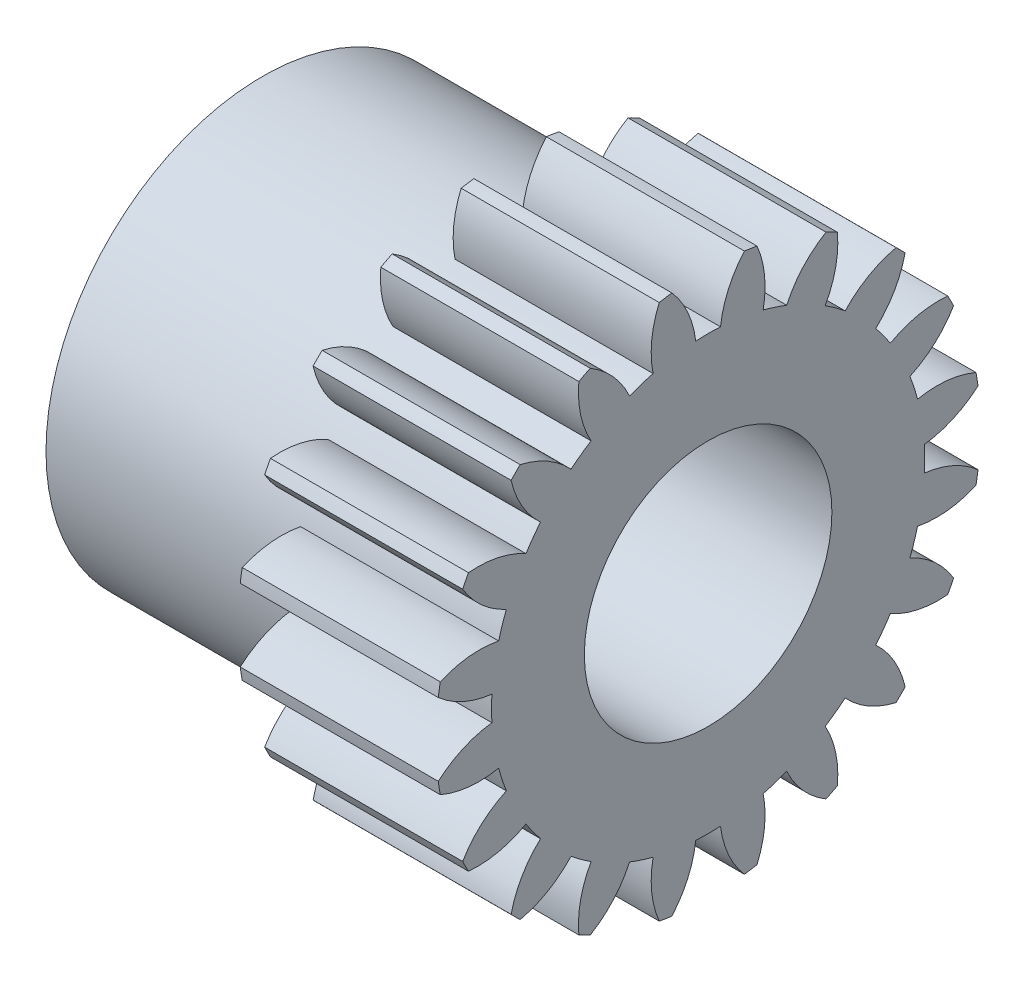
from build123d import *
from build123d.topology import SkipClean

# Parameters (mm, degrees)
BASPROSKE_W         = 5
BASPROSKE_H         = 5.5
TOOTHCUT_DEPTH      = 10.246621004
TEETHCUTS_COUNT     = 20
TEETHCUTS_ANGLE     = 342
HUBNEAONESKE_R      = 4.374
HUBNEARONE_DEPTH    = 5.0000508
BORSKE_R            = 2.5
BORE_DEPTH          = 10.0000508
SKETCH_1_R          = 5.5
CUT_EXTRUDE_1_DEPTH = 1


with BuildPart() as part:
    # BasProSke → Base-Revolve (revolve)
    with BuildSketch(Plane(origin=(0, 0, 0), x_dir=(1, 0, 0), z_dir=(0, 1, 0)), mode=Mode.PRIVATE) as base_revolve_sk:
        with Locations((2.5, 2.75)):
            Rectangle(BASPROSKE_W, BASPROSKE_H)
    revolve(base_revolve_sk.sketch.rotate(Axis((-10, 0, 0), (1, 0, 0)), 180), axis=Axis((-10, 0, 0), (1, 0, 0)))

    # TooCutSke → ToothCut (cut, through all)
    with BuildSketch(Plane(origin=(0, 0, 0), x_dir=(0, 0, -1), z_dir=(1, 0, 0))):
        with BuildLine():
            ThreePointArc((0.249903181, 4.366855207), (0, 4.374), (-0.249903181, 4.366855207))
            ThreePointArc((-0.249903181, 4.366855207), (-0.415207844, 4.95951031), (-0.752843848, 5.473871692))
            ThreePointArc((-0.752843848, 5.473871692), (0, 5.5254), (0.752843848, 5.473871692))
            ThreePointArc((0.752843848, 5.473871692), (0.415207844, 4.95951031), (0.249903181, 4.366855207))
        make_face()
    toothcut = extrude(amount=TOOTHCUT_DEPTH, mode=Mode.SUBTRACT)

    # TeethCuts: ToothCut ×20 about axis
    teethcuts_axis = Axis((-10, 0, 0), (1, 0, 0))
    for i in range(1, TEETHCUTS_COUNT):
        add(toothcut.rotate(teethcuts_axis, i * TEETHCUTS_ANGLE / (TEETHCUTS_COUNT - 1)), mode=Mode.SUBTRACT)

    # HubNeaOneSke → HubNearOne (add)
    with SkipClean():  # the faces are left unmerged after this step: merging them gives an invalid solid
        with BuildSketch(Plane.ZY):
            Circle(HUBNEAONESKE_R)
        extrude(amount=HUBNEARONE_DEPTH)

    # BorSke → Bore (cut, symmetric)
    with SkipClean():  # the faces are left unmerged after this step: merging them gives an invalid solid
        with BuildSketch(Plane(origin=(0, 0, 0), x_dir=(0, 0, -1), z_dir=(1, 0, 0))):
            with Locations(Location((0, 0, 0), (0, 0, 180))):
                Circle(BORSKE_R)
        extrude(amount=BORE_DEPTH, both=True, mode=Mode.SUBTRACT)

    # 草图1 → 切除-拉伸1 (cut)
    with SkipClean():  # the faces are left unmerged after this step: merging them gives an invalid solid
        with BuildSketch(Plane(origin=(5, 0, 0), x_dir=(0, 0, -1), z_dir=(1, 0, 0))):
            Circle(SKETCH_1_R)
        extrude(amount=-CUT_EXTRUDE_1_DEPTH, mode=Mode.SUBTRACT)


solid = part.part
